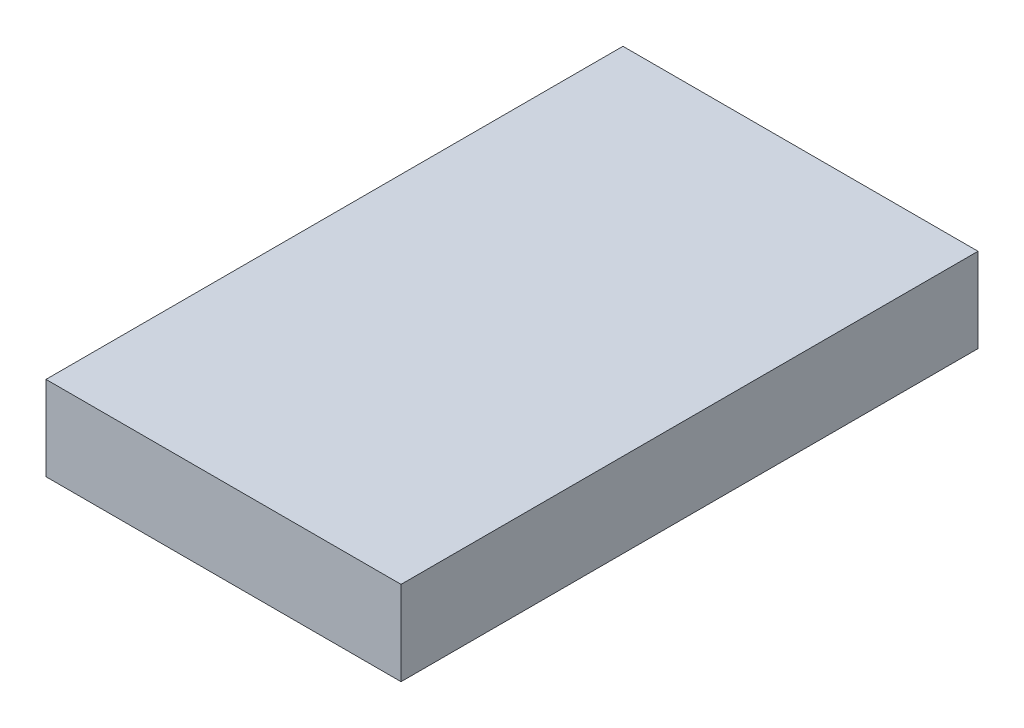
from build123d import *

# Parameters (mm, degrees)
CROQUIS1_W              = 160
CROQUIS1_H              = 38
SALIENTE_EXTRUIR1_DEPTH = 260


with BuildPart() as part:
    # Croquis1 → Saliente-Extruir1 (new body)
    with BuildSketch(Plane.XY):
        with Locations((80, 19)):
            Rectangle(CROQUIS1_W, CROQUIS1_H)
    extrude(amount=SALIENTE_EXTRUIR1_DEPTH)


solid = part.part
